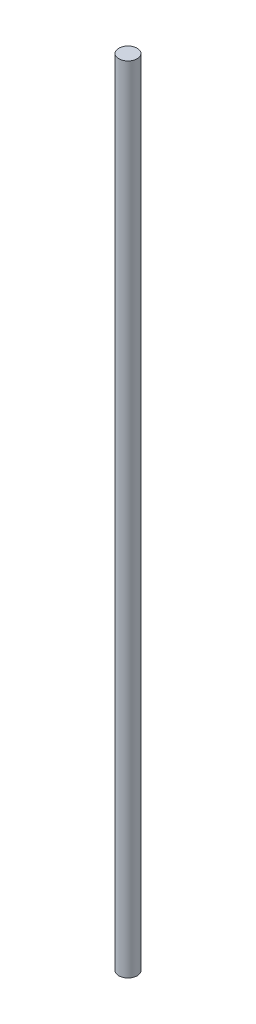
from build123d import *

# Parameters (mm, degrees)
SKETCH1_R           = 7.5
BOSS_EXTRUDE1_DEPTH = 650


with BuildPart() as part:
    # Sketch1 → Boss-Extrude1 (new body)
    with BuildSketch(Plane(origin=(0, 0, 0), x_dir=(1, 0, 0), z_dir=(0, 1, 0))):
        Circle(SKETCH1_R)
    extrude(amount=-BOSS_EXTRUDE1_DEPTH)


solid = part.part
